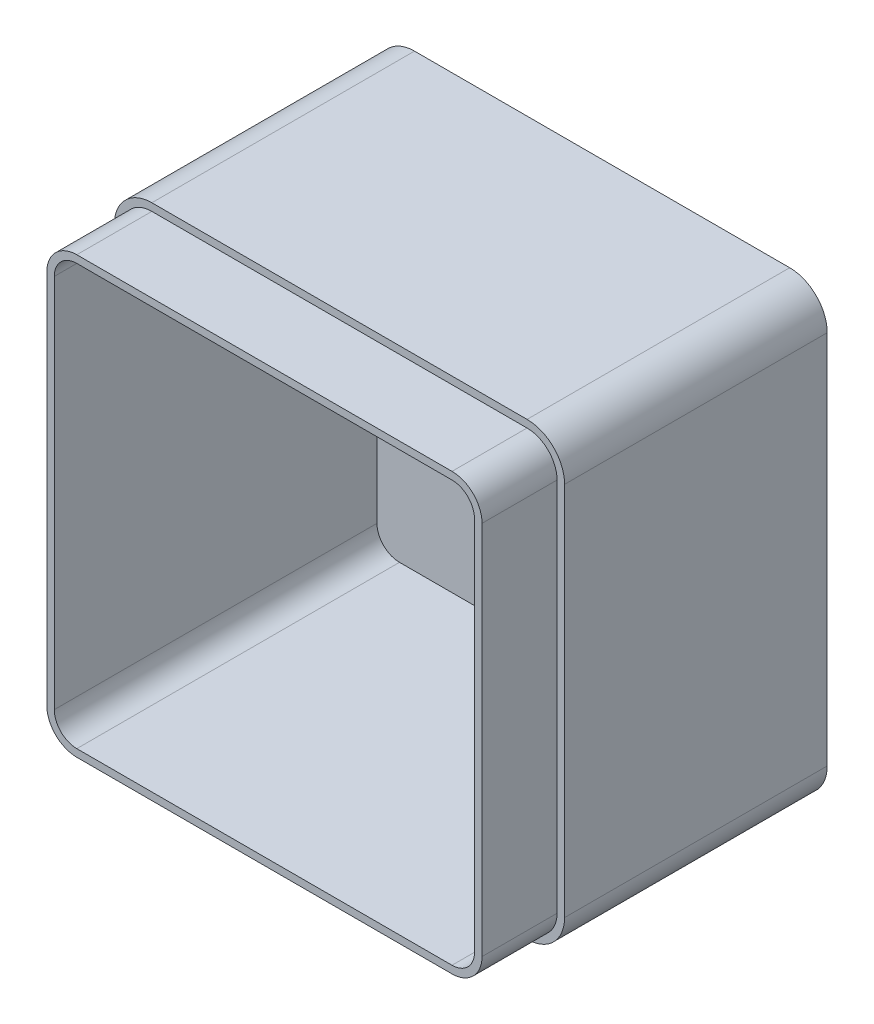
from build123d import *

# Parameters (mm, degrees)
SKETCH2_W           = 120
SKETCH2_H           = 120
BOSS_EXTRUDE1_DEPTH = 90
FILLET1_R           = 10
SHELL1_T            = -4
CUT_EXTRUDE1_DEPTH  = 20


with BuildPart() as part:
    # Sketch2 → Boss-Extrude1 (new body)
    with BuildSketch(Plane.XY):
        with Locations((3.41356674, -18.643326039)):
            Rectangle(SKETCH2_W, SKETCH2_H)
    extrude(amount=BOSS_EXTRUDE1_DEPTH)

    # Fillet1
    fillet1_edges = [part.edges().sort_by_distance(p)[0] for p in [
        (-56.58643326, 41.356673961, 45),
        (63.41356674, 41.356673961, 45),
        (63.41356674, -78.643326039, 45),
        (-56.58643326, -78.643326039, 45),
    ]]
    fillet(fillet1_edges, radius=FILLET1_R)

    # Shell1
    shell1_openings = [part.faces().sort_by_distance(p)[0] for p in [
        (3.41356674, -18.643326039, 90),
    ]]
    offset(amount=SHELL1_T, openings=shell1_openings, kind=Kind.INTERSECTION)

    # Sketch3 → Cut-Extrude1 (cut)
    with BuildSketch(Plane.XY.offset(90)):
        with BuildLine():
            Line((-56.58643326, 31.356673961), (-56.58643326, -68.643326039))
            ThreePointArc((-56.58643326, -68.643326039), (-53.657501072, -75.714393851), (-46.58643326, -78.643326039))
            Line((-46.58643326, -78.643326039), (53.41356674, -78.643326039))
            ThreePointArc((53.41356674, -78.643326039), (60.484634551, -75.714393851), (63.41356674, -68.643326039))
            Line((63.41356674, -68.643326039), (63.41356674, 31.356673961))
            ThreePointArc((63.41356674, 31.356673961), (60.484634551, 38.427741772), (53.41356674, 41.356673961))
            Line((53.41356674, 41.356673961), (-46.58643326, 41.356673961))
            ThreePointArc((-46.58643326, 41.356673961), (-53.657501072, 38.427741772), (-56.58643326, 31.356673961))
        make_face()
        with BuildLine():
            Line((-54.58643326, 31.356673961), (-54.58643326, -68.643326039))
            ThreePointArc((-54.58643326, -68.643326039), (-52.24328751, -74.300180289), (-46.58643326, -76.643326039))
            Line((-46.58643326, -76.643326039), (53.41356674, -76.643326039))
            ThreePointArc((53.41356674, -76.643326039), (59.070420989, -74.300180289), (61.41356674, -68.643326039))
            Line((61.41356674, -68.643326039), (61.41356674, 31.356673961))
            ThreePointArc((61.41356674, 31.356673961), (59.070420989, 37.01352821), (53.41356674, 39.356673961))
            Line((53.41356674, 39.356673961), (-46.58643326, 39.356673961))
            ThreePointArc((-46.58643326, 39.356673961), (-52.24328751, 37.01352821), (-54.58643326, 31.356673961))
        make_face(mode=Mode.SUBTRACT)
    extrude(amount=-CUT_EXTRUDE1_DEPTH, mode=Mode.SUBTRACT)


solid = part.part
